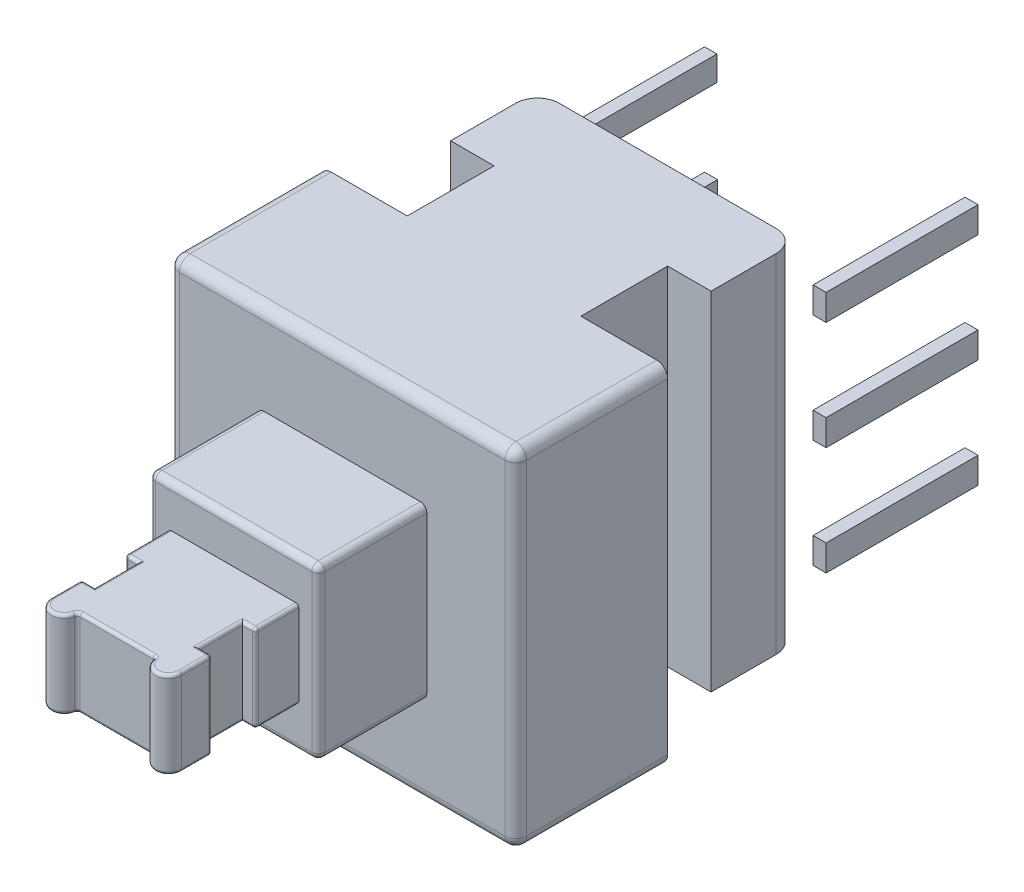
from build123d import *

# Parameters (mm, degrees)
SKETCH_1_W          = 8
SKETCH_1_H          = 8
EXTRUDE_1_DEPTH     = 8
SKETCH_3_W          = 3.9
SKETCH_3_H          = 3.9
EXTRUDE_2_DEPTH     = 2.5
SKETCH_4_W          = 3
SKETCH_4_H          = 2
EXTRUDE_3_DEPTH     = 3
SKETCH_5_W          = 0.3
SKETCH_5_H          = 0.6
SKETCH_5_W_2        = 0.285271027
SKETCH_5_H_2        = 0.570542054
EXTRUDE_4_DEPTH     = 3.5
SKETCH_6_W          = 0.3
SKETCH_6_H          = 1
CUT_EXTRUDE_1_DEPTH = 2
CUT_EXTRUDE_3_DEPTH = 2
FILLET_1_R          = 0.25
FILLET_2_R          = 0.15
FILLET_3_R          = 0.07
CUT_EXTRUDE_5_DEPTH = 9


with BuildPart() as part:
    # 草圖1 → 填料-伸長1 (new body)
    with BuildSketch(Plane.XY):
        Rectangle(SKETCH_1_W, SKETCH_1_H)
    extrude(amount=EXTRUDE_1_DEPTH)

    # 草圖3 → 填料-伸長2 (add)
    with BuildSketch(Plane.XY.offset(8)):
        Rectangle(SKETCH_3_W, SKETCH_3_H)
    extrude(amount=EXTRUDE_2_DEPTH)

    # 草圖4 → 填料-伸長3 (add)
    with BuildSketch(Plane.XY.offset(10.5)):
        Rectangle(SKETCH_4_W, SKETCH_4_H)
    extrude(amount=EXTRUDE_3_DEPTH)

    # 草圖5 → 填料-伸長4 (add)
    with BuildSketch(Plane(origin=(0, 0, 0), x_dir=(-1, 0, 0), z_dir=(0, 0, -1))):
        with Locations((-3, 0)):
            Rectangle(SKETCH_5_W, SKETCH_5_H)
        with Locations((-3, 2.5)):
            Rectangle(SKETCH_5_W, SKETCH_5_H)
        with Locations((-3, -2.5)):
            Rectangle(SKETCH_5_W, SKETCH_5_H)
        with Locations((3, -2.5)):
            Rectangle(SKETCH_5_W, SKETCH_5_H)
        with Locations((3, 0)):
            Rectangle(SKETCH_5_W, SKETCH_5_H)
        with Locations((3.007364487, 2.514728973)):
            Rectangle(SKETCH_5_W_2, SKETCH_5_H_2)
    extrude(amount=EXTRUDE_4_DEPTH)

    # 草圖6 → 除料-伸長1 (cut)
    with BuildSketch(Plane.XZ.offset(1)):
        with Locations((-1.35, 12)):
            Rectangle(SKETCH_6_W, SKETCH_6_H)
        with Locations((1.35, 12)):
            Rectangle(SKETCH_6_W, SKETCH_6_H)
    extrude(amount=-CUT_EXTRUDE_1_DEPTH, mode=Mode.SUBTRACT)

    # 草圖7 → 除料-伸長3 (cut)
    with BuildSketch(Plane.XZ.offset(1)):
        with BuildLine():
            ThreePointArc((-1.5, 13.2), (-1.412132034, 13.412132034), (-1.2, 13.5))
            Line((-1.2, 13.5), (-1.5, 13.5))
            Line((-1.5, 13.5), (-1.5, 13.2))
        make_face()
        with BuildLine():
            Line((-0.9, 13.2), (0, 13.2))
            Line((0, 13.2), (0.9, 13.2))
            ThreePointArc((0.9, 13.2), (0.987867966, 13.412132034), (1.2, 13.5))
            Line((1.2, 13.5), (0, 13.5))
            Line((0, 13.5), (-1.2, 13.5))
            ThreePointArc((-1.2, 13.5), (-0.987867966, 13.412132034), (-0.9, 13.2))
        make_face()
        with BuildLine():
            Line((1.5, 13.5), (1.2, 13.5))
            ThreePointArc((1.2, 13.5), (1.412132034, 13.412132034), (1.5, 13.2))
            Line((1.5, 13.2), (1.5, 13.5))
        make_face()
    extrude(amount=-CUT_EXTRUDE_3_DEPTH, mode=Mode.SUBTRACT)

    # 圓角1
    fillet_1_edges = [part.edges().sort_by_distance(p)[0] for p in [
        (-4, 0, 8),
        (0, -4, 8),
        (4, 0, 8),
        (0, -4, 0),
        (-4, 0, 0),
        (0, 4, 0),
        (4, 0, 0),
        (0, 4, 8),
        (4, -4, 4),
        (-4, -4, 4),
        (-4, 4, 4),
        (4, 4, 4),
    ]]
    fillet(fillet_1_edges, radius=FILLET_1_R)

    # 圓角2
    fillet_2_edges = [part.edges().sort_by_distance(p)[0] for p in [
        (1.95, -1.95, 9.25),
        (1.95, 1.95, 9.25),
        (-1.95, 1.95, 9.25),
        (-1.95, -1.95, 9.25),
        (1.95, 0, 10.5),
        (0, 1.95, 10.5),
        (-1.95, 0, 10.5),
        (0, -1.95, 10.5),
    ]]
    fillet(fillet_2_edges, radius=FILLET_2_R)

    # 圓角3
    fillet_3_edges = [part.edges().sort_by_distance(p)[0] for p in [
        (1.5, -1, 11),
        (1.5, 1, 11),
        (1.5, 0, 12.5),
        (1.5, 0, 11.5),
        (1.35, -1, 12.5),
        (1.2, -1, 12),
        (1.35, -1, 11.5),
        (1.35, 1, 12.5),
        (1.35, 1, 11.5),
        (1.2, 1, 12),
        (-1.5, -1, 11),
        (-1.5, 1, 11),
        (-1.5, 0, 12.5),
        (-1.5, 0, 11.5),
        (-1.35, -1, 12.5),
        (-1.35, -1, 11.5),
        (-1.2, -1, 12),
        (-1.35, 1, 12.5),
        (-1.2, 1, 12),
        (-1.35, 1, 11.5),
        (-1.5, -1, 12.85),
        (-1.5, 1, 12.85),
        (-1.2, -1, 13.5),
        (-1.2, 1, 13.5),
        (1.2, 1, 13.5),
        (1.2, -1, 13.5),
        (0, 1, 13.2),
        (0.9, 0, 13.2),
        (0, -1, 13.2),
        (-0.9, 0, 13.2),
        (1.5, -1, 12.85),
        (1.5, 1, 12.85),
    ]]
    fillet(fillet_3_edges, radius=FILLET_3_R)

    # 草圖9 → 除料-伸長5 (cut, through all)
    with BuildSketch(Plane.XZ.offset(4)):
        with BuildLine():
            Line((-4, 0), (-4, 4.5))
            Line((-4, 4.5), (-2, 4.5))
            Line((-2, 4.5), (-2, 2.5))
            Line((-2, 2.5), (-3, 2.5))
            Line((-3, 2.5), (-3, 1))
            ThreePointArc((-3, 1), (-2.853553391, 0.646446609), (-2.5, 0.5))
            Line((-2.5, 0.5), (2.5, 0.5))
            ThreePointArc((2.5, 0.5), (2.853553391, 0.646446609), (3, 1))
            Line((3, 1), (3, 2.5))
            Line((3, 2.5), (2, 2.5))
            Line((2, 2.5), (2, 4.5))
            Line((2, 4.5), (4, 4.5))
            Line((4, 4.5), (4, 0))
            Line((4, 0), (-4, 0))
        make_face()
    extrude(amount=-CUT_EXTRUDE_5_DEPTH, mode=Mode.SUBTRACT)


solid = part.part
